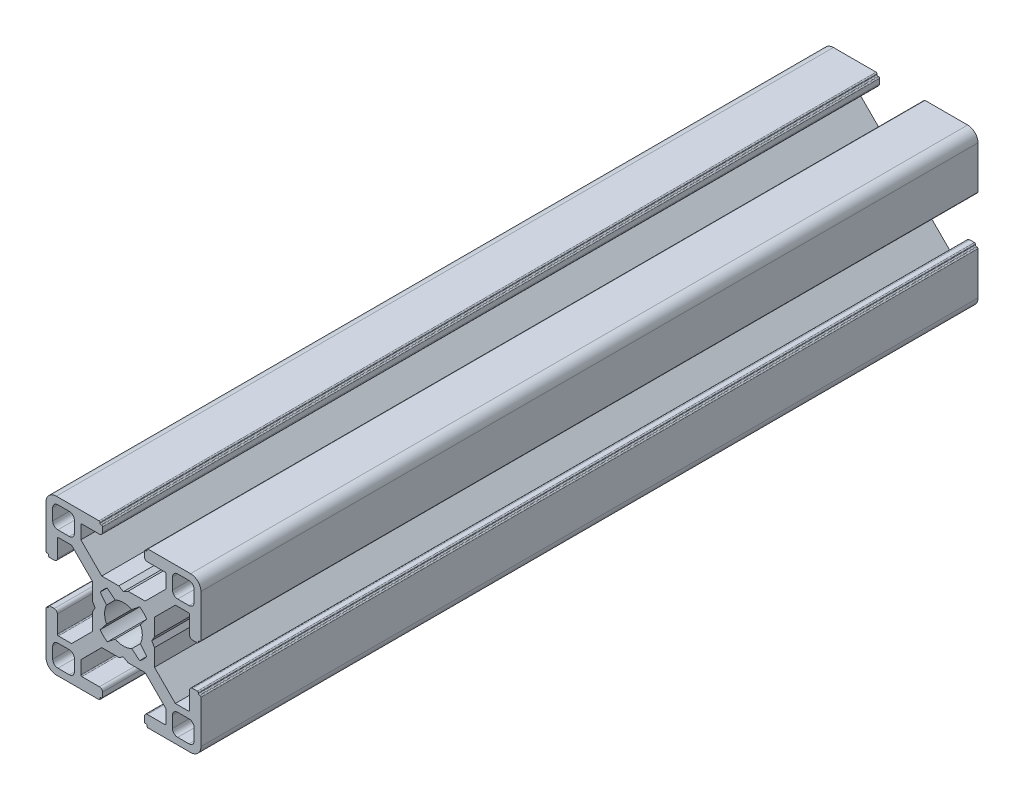
from build123d import *

# Parameters (mm, degrees)
BASE_EXTRUDE_DEPTH = 70
SCALE1_SCALE_X     = 1
SCALE1_SCALE_Y     = 1
SCALE1_SCALE_Z     = 2.15


with BuildPart() as part:
    # Sketch1 → Base-Extrude (new body)
    with BuildSketch(Plane.XY):
        with BuildLine():
            Line((6.00446543, 0.899999619), (5.484852164, 0))
            Line((5.484852164, 0), (6.00446543, -0.899999619))
            Line((6.00446543, -0.899999619), (6.00446543, -4.204465866))
            Line((6.00446543, -4.204465866), (10.049999564, -8.25))
            Line((10.049999564, -8.25), (12.59999928, -8.25))
            ThreePointArc((12.59999928, -8.25), (12.741420837, -8.191421273), (12.799999564, -8.049999716))
            Line((12.799999564, -8.049999716), (12.799999564, -4.649999613))
            ThreePointArc((12.799999564, -4.649999613), (12.975735606, -4.225735278), (13.39999994, -4.049999237))
            Line((13.39999994, -4.049999237), (14.300000043, -4.049999237))
            ThreePointArc((14.300000043, -4.049999237), (14.4414216, -4.108577964), (14.500000327, -4.249999521))
            Line((14.500000327, -4.249999521), (14.500000327, -4.349998953))
            ThreePointArc((14.500000327, -4.349998953), (14.558579054, -4.49142051), (14.700000611, -4.549999237))
            Line((14.700000611, -4.549999237), (14.799999716, -4.549999237))
            ThreePointArc((14.799999716, -4.549999237), (14.941421273, -4.608577964), (15, -4.749999521))
            Line((15, -4.749999521), (15, -13.000000346))
            ThreePointArc((15, -13.000000346), (14.414213664, -14.414213664), (13.000000346, -15))
            Line((13.000000346, -15), (4.749999945, -15))
            ThreePointArc((4.749999945, -15), (4.60857832, -14.941421245), (4.549999564, -14.799999619))
            Line((4.549999564, -14.799999619), (4.549999564, -14.69999942))
            ThreePointArc((4.549999564, -14.69999942), (4.49142109, -14.558578474), (4.350000144, -14.5))
            Line((4.350000144, -14.5), (4.250000374, -14.5))
            ThreePointArc((4.250000374, -14.5), (4.108578753, -14.441421247), (4.05, -14.299999626))
            Line((4.05, -14.299999626), (4.05, -13.399999434))
            ThreePointArc((4.05, -13.399999434), (4.225735989, -12.975735226), (4.650000197, -12.799999237))
            Line((4.650000197, -12.799999237), (8.049999924, -12.799999237))
            ThreePointArc((8.049999924, -12.799999237), (8.191421565, -12.741420475), (8.250000327, -12.599998834))
            Line((8.250000327, -12.599998834), (8.250000327, -10.049999237))
            Line((8.250000327, -10.049999237), (4.204466193, -6))
            Line((4.204466193, -6), (0.899999946, -6))
            Line((0.899999946, -6), (0, -5.484851837))
            Line((0, -5.484851837), (-0.899999946, -6))
            Line((-0.899999946, -6), (-4.204466193, -6))
            Line((-4.204466193, -6), (-8.250000327, -10.049999237))
            Line((-8.250000327, -10.049999237), (-8.250000327, -12.599998834))
            ThreePointArc((-8.250000327, -12.599998834), (-8.191421565, -12.741420475), (-8.049999924, -12.799999237))
            Line((-8.049999924, -12.799999237), (-4.650000197, -12.799999237))
            ThreePointArc((-4.650000197, -12.799999237), (-4.225735989, -12.975735226), (-4.05, -13.399999434))
            Line((-4.05, -13.399999434), (-4.05, -14.299999626))
            ThreePointArc((-4.05, -14.299999626), (-4.108578753, -14.441421247), (-4.250000374, -14.5))
            Line((-4.250000374, -14.5), (-4.350000144, -14.5))
            ThreePointArc((-4.350000144, -14.5), (-4.49142109, -14.558578474), (-4.549999564, -14.69999942))
            Line((-4.549999564, -14.69999942), (-4.549999564, -14.799999619))
            ThreePointArc((-4.549999564, -14.799999619), (-4.60857832, -14.941421245), (-4.749999945, -15))
            Line((-4.749999945, -15), (-13.000000346, -15))
            ThreePointArc((-13.000000346, -15), (-14.414213664, -14.414213664), (-15, -13.000000346))
            Line((-15, -13.000000346), (-15, -4.749999521))
            ThreePointArc((-15, -4.749999521), (-14.941421273, -4.608577964), (-14.799999716, -4.549999237))
            Line((-14.799999716, -4.549999237), (-14.700000611, -4.549999237))
            ThreePointArc((-14.700000611, -4.549999237), (-14.558579054, -4.49142051), (-14.500000327, -4.349998953))
            Line((-14.500000327, -4.349998953), (-14.500000327, -4.249999521))
            ThreePointArc((-14.500000327, -4.249999521), (-14.4414216, -4.108577964), (-14.300000043, -4.049999237))
            Line((-14.300000043, -4.049999237), (-13.39999994, -4.049999237))
            ThreePointArc((-13.39999994, -4.049999237), (-12.975735606, -4.225735278), (-12.799999564, -4.649999613))
            Line((-12.799999564, -4.649999613), (-12.799999564, -8.049999716))
            ThreePointArc((-12.799999564, -8.049999716), (-12.741420837, -8.191421273), (-12.59999928, -8.25))
            Line((-12.59999928, -8.25), (-10.049999564, -8.25))
            Line((-10.049999564, -8.25), (-6.00446543, -4.204465866))
            Line((-6.00446543, -4.204465866), (-6.00446543, -0.899999619))
            Line((-6.00446543, -0.899999619), (-5.484852164, 0))
            Line((-5.484852164, 0), (-6.00446543, 0.899999619))
            Line((-6.00446543, 0.899999619), (-6.00446543, 4.204465866))
            Line((-6.00446543, 4.204465866), (-10.049999564, 8.25))
            Line((-10.049999564, 8.25), (-12.59999928, 8.25))
            ThreePointArc((-12.59999928, 8.25), (-12.741420837, 8.191421273), (-12.799999564, 8.049999716))
            Line((-12.799999564, 8.049999716), (-12.799999564, 4.649999613))
            ThreePointArc((-12.799999564, 4.649999613), (-12.975735606, 4.225735278), (-13.39999994, 4.049999237))
            Line((-13.39999994, 4.049999237), (-14.300000043, 4.049999237))
            ThreePointArc((-14.300000043, 4.049999237), (-14.4414216, 4.108577964), (-14.500000327, 4.249999521))
            Line((-14.500000327, 4.249999521), (-14.500000327, 4.349998953))
            ThreePointArc((-14.500000327, 4.349998953), (-14.558579054, 4.49142051), (-14.700000611, 4.549999237))
            Line((-14.700000611, 4.549999237), (-14.799999716, 4.549999237))
            ThreePointArc((-14.799999716, 4.549999237), (-14.941421273, 4.608577964), (-15, 4.749999521))
            Line((-15, 4.749999521), (-15, 13.000000346))
            ThreePointArc((-15, 13.000000346), (-14.414213664, 14.414213664), (-13.000000346, 15))
            Line((-13.000000346, 15), (-4.749999945, 15))
            ThreePointArc((-4.749999945, 15), (-4.60857832, 14.941421245), (-4.549999564, 14.799999619))
            Line((-4.549999564, 14.799999619), (-4.549999564, 14.69999942))
            ThreePointArc((-4.549999564, 14.69999942), (-4.49142109, 14.558578474), (-4.350000144, 14.5))
            Line((-4.350000144, 14.5), (-4.250000374, 14.5))
            ThreePointArc((-4.250000374, 14.5), (-4.108578753, 14.441421247), (-4.05, 14.299999626))
            Line((-4.05, 14.299999626), (-4.05, 13.399999434))
            ThreePointArc((-4.05, 13.399999434), (-4.225735989, 12.975735226), (-4.650000197, 12.799999237))
            Line((-4.650000197, 12.799999237), (-8.049999924, 12.799999237))
            ThreePointArc((-8.049999924, 12.799999237), (-8.191421565, 12.741420475), (-8.250000327, 12.599998834))
            Line((-8.250000327, 12.599998834), (-8.250000327, 10.049999237))
            Line((-8.250000327, 10.049999237), (-4.204466193, 6))
            Line((-4.204466193, 6), (-0.899999946, 6))
            Line((-0.899999946, 6), (0, 5.484851837))
            Line((0, 5.484851837), (0.899999946, 6))
            Line((0.899999946, 6), (4.204466193, 6))
            Line((4.204466193, 6), (8.250000327, 10.049999237))
            Line((8.250000327, 10.049999237), (8.250000327, 12.599998834))
            ThreePointArc((8.250000327, 12.599998834), (8.191421565, 12.741420475), (8.049999924, 12.799999237))
            Line((8.049999924, 12.799999237), (4.650000197, 12.799999237))
            ThreePointArc((4.650000197, 12.799999237), (4.225735989, 12.975735226), (4.05, 13.399999434))
            Line((4.05, 13.399999434), (4.05, 14.299999626))
            ThreePointArc((4.05, 14.299999626), (4.108578753, 14.441421247), (4.250000374, 14.5))
            Line((4.250000374, 14.5), (4.350000144, 14.5))
            ThreePointArc((4.350000144, 14.5), (4.49142109, 14.558578474), (4.549999564, 14.69999942))
            Line((4.549999564, 14.69999942), (4.549999564, 14.799999619))
            ThreePointArc((4.549999564, 14.799999619), (4.60857832, 14.941421245), (4.749999945, 15))
            Line((4.749999945, 15), (13.000000346, 15))
            ThreePointArc((13.000000346, 15), (14.414213664, 14.414213664), (15, 13.000000346))
            Line((15, 13.000000346), (15, 4.749999521))
            ThreePointArc((15, 4.749999521), (14.941421273, 4.608577964), (14.799999716, 4.549999237))
            Line((14.799999716, 4.549999237), (14.700000611, 4.549999237))
            ThreePointArc((14.700000611, 4.549999237), (14.558579054, 4.49142051), (14.500000327, 4.349998953))
            Line((14.500000327, 4.349998953), (14.500000327, 4.249999521))
            ThreePointArc((14.500000327, 4.249999521), (14.4414216, 4.108577964), (14.300000043, 4.049999237))
            Line((14.300000043, 4.049999237), (13.39999994, 4.049999237))
            ThreePointArc((13.39999994, 4.049999237), (12.975735606, 4.225735278), (12.799999564, 4.649999613))
            Line((12.799999564, 4.649999613), (12.799999564, 8.049999716))
            ThreePointArc((12.799999564, 8.049999716), (12.741420837, 8.191421273), (12.59999928, 8.25))
            Line((12.59999928, 8.25), (10.049999564, 8.25))
            Line((10.049999564, 8.25), (6.00446543, 4.204465866))
            Line((6.00446543, 4.204465866), (6.00446543, 0.899999619))
        make_face()
        with BuildLine():
            Line((13.70000109, 12.700000408), (13.70000109, 10.499999626))
            ThreePointArc((13.70000109, 10.499999626), (13.407107874, 9.792892851), (12.7000011, 9.499999635))
            Line((12.7000011, 9.499999635), (10.500000318, 9.499999635))
            ThreePointArc((10.500000318, 9.499999635), (9.792893543, 9.792892851), (9.500000327, 10.499999626))
            Line((9.500000327, 10.499999626), (9.500000327, 12.700000408))
            ThreePointArc((9.500000327, 12.700000408), (9.792893543, 13.407107182), (10.500000318, 13.700000398))
            Line((10.500000318, 13.700000398), (12.7000011, 13.700000398))
            ThreePointArc((12.7000011, 13.700000398), (13.407107874, 13.407107182), (13.70000109, 12.700000408))
        make_face(mode=Mode.SUBTRACT)
        with BuildLine():
            Line((3.135929412, 4.518400903), (1.600129524, 3.280561767))
            ThreePointArc((1.600129524, 3.280561767), (0, 3.65), (-1.600129524, 3.280561767))
            Line((-1.600129524, 3.280561767), (-3.135929412, 4.518400903))
            ThreePointArc((-3.135929412, 4.518400903), (-3.881002259, 3.897155561), (-4.505336892, 3.154669473))
            Line((-4.505336892, 3.154669473), (-3.280561732, 1.600129597))
            ThreePointArc((-3.280561732, 1.600129597), (-3.65, 0), (-3.280561732, -1.600129597))
            Line((-3.280561732, -1.600129597), (-4.505336892, -3.154669473))
            ThreePointArc((-4.505336892, -3.154669473), (-3.881002259, -3.897155561), (-3.135929412, -4.518400903))
            Line((-3.135929412, -4.518400903), (-1.600129524, -3.280561767))
            ThreePointArc((-1.600129524, -3.280561767), (0, -3.65), (1.600129524, -3.280561767))
            Line((1.600129524, -3.280561767), (3.135929412, -4.518400903))
            ThreePointArc((3.135929412, -4.518400903), (3.881002259, -3.897155561), (4.505336892, -3.154669473))
            Line((4.505336892, -3.154669473), (3.280561732, -1.600129597))
            ThreePointArc((3.280561732, -1.600129597), (3.65, 0), (3.280561732, 1.600129597))
            Line((3.280561732, 1.600129597), (4.505336892, 3.154669473))
            ThreePointArc((4.505336892, 3.154669473), (3.881002259, 3.897155561), (3.135929412, 4.518400903))
        make_face(mode=Mode.SUBTRACT)
        with BuildLine():
            Line((-13.70000109, -12.700000408), (-13.70000109, -10.499999626))
            ThreePointArc((-13.70000109, -10.499999626), (-13.407107874, -9.792892851), (-12.7000011, -9.499999635))
            Line((-12.7000011, -9.499999635), (-10.500000318, -9.499999635))
            ThreePointArc((-10.500000318, -9.499999635), (-9.792893543, -9.792892851), (-9.500000327, -10.499999626))
            Line((-9.500000327, -10.499999626), (-9.500000327, -12.700000408))
            ThreePointArc((-9.500000327, -12.700000408), (-9.792893543, -13.407107182), (-10.500000318, -13.700000398))
            Line((-10.500000318, -13.700000398), (-12.7000011, -13.700000398))
            ThreePointArc((-12.7000011, -13.700000398), (-13.407107874, -13.407107182), (-13.70000109, -12.700000408))
        make_face(mode=Mode.SUBTRACT)
        with BuildLine():
            Line((10.500000318, -13.700000398), (12.7000011, -13.700000398))
            ThreePointArc((12.7000011, -13.700000398), (13.407107874, -13.407107182), (13.70000109, -12.700000408))
            Line((13.70000109, -12.700000408), (13.70000109, -10.499999626))
            ThreePointArc((13.70000109, -10.499999626), (13.407107874, -9.792892851), (12.7000011, -9.499999635))
            Line((12.7000011, -9.499999635), (10.500000318, -9.499999635))
            ThreePointArc((10.500000318, -9.499999635), (9.792893543, -9.792892851), (9.500000327, -10.499999626))
            Line((9.500000327, -10.499999626), (9.500000327, -12.700000408))
            ThreePointArc((9.500000327, -12.700000408), (9.792893543, -13.407107182), (10.500000318, -13.700000398))
        make_face(mode=Mode.SUBTRACT)
        with BuildLine():
            Line((-10.500000318, 13.700000398), (-12.7000011, 13.700000398))
            ThreePointArc((-12.7000011, 13.700000398), (-13.407107874, 13.407107182), (-13.70000109, 12.700000408))
            Line((-13.70000109, 12.700000408), (-13.70000109, 10.499999626))
            ThreePointArc((-13.70000109, 10.499999626), (-13.407107874, 9.792892851), (-12.7000011, 9.499999635))
            Line((-12.7000011, 9.499999635), (-10.500000318, 9.499999635))
            ThreePointArc((-10.500000318, 9.499999635), (-9.792893543, 9.792892851), (-9.500000327, 10.499999626))
            Line((-9.500000327, 10.499999626), (-9.500000327, 12.700000408))
            ThreePointArc((-9.500000327, 12.700000408), (-9.792893543, 13.407107182), (-10.500000318, 13.700000398))
        make_face(mode=Mode.SUBTRACT)
    extrude(amount=-BASE_EXTRUDE_DEPTH)


with BuildPart() as part_1:
    # Scale1: scaled about (0, 0, 0)
    add(part.part.scale((SCALE1_SCALE_X, SCALE1_SCALE_Y, SCALE1_SCALE_Z), about=(0, 0, 0)))


solid = part_1.part
